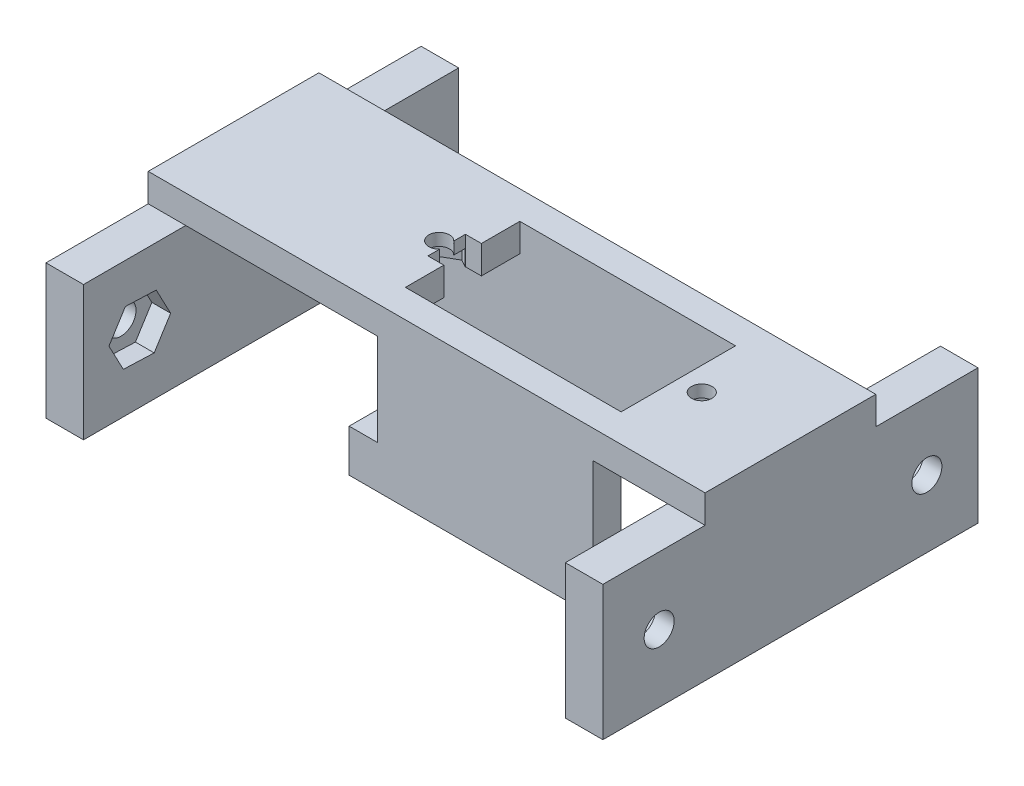
from build123d import *

# Parameters (mm, degrees)
BOSS_EXTRUDE1_DEPTH      = 3
SKETCH2_W                = 5
SKETCH2_H                = 3
SKETCH2_W_2              = 3
SKETCH2_H_2              = 4.533238731
BOSS_EXTRUDE2_DEPTH      = 15.2
BOSS_EXTRUDE3_DEPTH      = 3
BOSS_EXTRUDE4_DEPTH      = 19.425
BOSS_EXTRUDE5_DEPTH      = 6.955
CUT_EXTRUDE1_REACH       = 19.35
SKETCH6_R                = 1.1
CUT_EXTRUDE2_DEPTH       = 1.7
SKETCH8_W                = 4
SKETCH8_H                = 14.35
BOSS_EXTRUDE6_DEPTH      = 26.1
BOSS_EXTRUDE6_DEPTH_BACK = 13.9
SKETCH10_R               = 1.6
CUT_EXTRUDE3_DEPTH       = 56.38
CUT_EXTRUDE3_DEPTH_BACK  = 5
CUT_EXTRUDE5_START       = -2
CUT_EXTRUDE5_DEPTH       = 55.38
CUT_EXTRUDE6_DEPTH       = 7.5
CUT_EXTRUDE6_DEPTH_BACK  = 15.316761
CUT_EXTRUDE7_REACH       = 24.725
SKETCH13_W               = 4
SKETCH13_H               = 2.5


with BuildPart() as part:
    # Sketch1 → Boss-Extrude1 (new body)
    with BuildSketch(Plane.XY):
        Polygon((16.5, 0), (16.5, -3), (11.5, -3), (11.5, -12.816761269), (14.5, -12.816761269), (14.5, -17.35), (-14.5, -17.35), (-14.5, -12.816761269), (-11.5, -12.816761269), (-11.5, -3), (-16.5, -3), (-16.5, 0), align=None)
    extrude(amount=BOSS_EXTRUDE1_DEPTH)

    # Sketch2 → Boss-Extrude2 (add)
    with BuildSketch(Plane(origin=(0, 0, 0), x_dir=(-1, 0, 0), z_dir=(0, 0, -1))):
        with Locations((-14, -1.5)):
            Rectangle(SKETCH2_W, SKETCH2_H)
        with Locations((14, -1.5)):
            Rectangle(SKETCH2_W, SKETCH2_H)
        with Locations((-13, -15.083380635)):
            Rectangle(SKETCH2_W_2, SKETCH2_H_2)
        with Locations((13, -15.083380635)):
            Rectangle(SKETCH2_W_2, SKETCH2_H_2)
    extrude(amount=BOSS_EXTRUDE2_DEPTH)

    # Sketch3 → Boss-Extrude3 (add)
    with BuildSketch(Plane(origin=(0, 0, -12.2), x_dir=(-1, 0, 0), z_dir=(0, 0, -1))):
        Polygon((-11.5, -17.35), (16.5, -17.35), (16.5, 0), (-16.5, 0), (-16.5, -17.35), align=None)
    extrude(amount=BOSS_EXTRUDE3_DEPTH)

    # Sketch4 → Boss-Extrude4 (add)
    with BuildSketch(Plane.ZY.offset(16.5)):
        Polygon((-15.2, -17.35), (-12.2, -17.35), (-12.2, -3), (3, -3), (3, 0), (-15.2, 0), align=None)
    extrude(amount=BOSS_EXTRUDE4_DEPTH)

    # Sketch5 → Boss-Extrude5 (add)
    with BuildSketch(Plane(origin=(16.5, 0, 0), x_dir=(0, 0, -1), z_dir=(1, 0, 0))):
        Polygon((-3, 0), (15.2, 0), (15.2, -17.35), (12.2, -17.35), (12.2, -3), (-3, -3), align=None)
    extrude(amount=BOSS_EXTRUDE5_DEPTH)

    # Sketch6 → Cut-Extrude1 (cut, up to next)
    with BuildSketch(Plane(origin=(0, 0, 0), x_dir=(1, 0, 0), z_dir=(0, 1, 0)), mode=Mode.PRIVATE) as cut_extrude1_sk1:
        with Locations((14, 6.1)):
            Circle(SKETCH6_R)
    cut_extrude1_tool1 = extrude(cut_extrude1_sk1.sketch, amount=-CUT_EXTRUDE1_REACH, mode=Mode.PRIVATE) & part.part
    add(cut_extrude1_tool1.solids().sort_by_distance((14, 0, -6.1))[0], mode=Mode.SUBTRACT)
    # Sketch6 → Cut-Extrude1 (cut, up to next)
    with BuildSketch(Plane(origin=(0, 0, 0), x_dir=(1, 0, 0), z_dir=(0, 1, 0)), mode=Mode.PRIVATE) as cut_extrude1_sk2:
        with Locations((-14, 6.1)):
            Circle(SKETCH6_R)
    cut_extrude1_tool2 = extrude(cut_extrude1_sk2.sketch, amount=-CUT_EXTRUDE1_REACH, mode=Mode.PRIVATE) & part.part
    add(cut_extrude1_tool2.solids().sort_by_distance((-14, 0, -6.1))[0], mode=Mode.SUBTRACT)

    # Sketch7 → Cut-Extrude2 (cut)
    with BuildSketch(Plane.XZ.offset(3)):
        Polygon((14, -3.675128869), (11.9, -4.887564435), (11.9, -7.312435565), (14, -8.524871131), (16.1, -7.312435565), (16.1, -4.887564435), align=None)
        Polygon((-14, -3.675128869), (-16.1, -4.887564435), (-16.1, -7.312435565), (-14, -8.524871131), (-11.9, -7.312435565), (-11.9, -4.887564435), align=None)
    extrude(amount=-CUT_EXTRUDE2_DEPTH, mode=Mode.SUBTRACT)

    # Sketch8 → Boss-Extrude6 (add, two sides)
    with BuildSketch(Plane.XY.offset(-12.2)) as boss_extrude6_sk:
        with Locations((-33.925, -10.175)):
            Rectangle(SKETCH8_W, SKETCH8_H)
        with Locations((21.455, -10.175)):
            Rectangle(SKETCH8_W, SKETCH8_H)
    extrude(amount=BOSS_EXTRUDE6_DEPTH)
    extrude(boss_extrude6_sk.sketch, amount=-BOSS_EXTRUDE6_DEPTH_BACK)

    # Sketch10 → Cut-Extrude3 (cut, two sides)
    with BuildSketch(Plane(origin=(-31.925, 0, 0), x_dir=(0, 0, -1), z_dir=(1, 0, 0))) as cut_extrude3_sk:
        with Locations((-7.9, -10.175)):
            Circle(SKETCH10_R)
        with Locations((20.65, -10.175)):
            Circle(SKETCH10_R)
    extrude(amount=CUT_EXTRUDE3_DEPTH, mode=Mode.SUBTRACT)
    extrude(cut_extrude3_sk.sketch, amount=-CUT_EXTRUDE3_DEPTH_BACK, mode=Mode.SUBTRACT)

    # Sketch11 → Cut-Extrude5 (cut)
    with BuildSketch(Plane(origin=(-31.925, 0, 0), x_dir=(0, 0, -1), z_dir=(1, 0, 0)).offset(CUT_EXTRUDE5_START)):
        Polygon((-9.652389588, -12.960521627), (-6.363862302, -13.085374714), (-4.611472715, -10.299853087), (-6.147610412, -7.389478373), (-9.436137698, -7.264625286), (-11.188527285, -10.050146913), align=None)
        Polygon((20.65, -13.465896534), (23.5, -11.820448267), (23.5, -8.529551733), (20.65, -6.884103466), (17.8, -8.529551733), (17.8, -11.820448267), align=None)
    extrude(amount=CUT_EXTRUDE5_DEPTH, mode=Mode.SUBTRACT)

    # Sketch12 → Cut-Extrude6 (cut, two sides)
    with BuildSketch(Plane(origin=(0, 0, 0), x_dir=(1, 0, 0), z_dir=(0, 1, 0))) as cut_extrude6_sk:
        Polygon((-11.5, 6.1), (-11.5, 4.1), (-13.2, 4.1), (-13.2, 8.1), (-11.5, 8.1), align=None)
    extrude(amount=CUT_EXTRUDE6_DEPTH, mode=Mode.SUBTRACT)
    extrude(cut_extrude6_sk.sketch, amount=-CUT_EXTRUDE6_DEPTH_BACK, mode=Mode.SUBTRACT)

    # Sketch13 → Cut-Extrude7 (cut, up to next)
    with BuildSketch(Plane(origin=(-13.2, 0, 0), x_dir=(0, 0, -1), z_dir=(1, 0, 0)), mode=Mode.PRIVATE) as cut_extrude7_sk1:
        with Locations((6.1, -14.066761269)):
            Rectangle(SKETCH13_W, SKETCH13_H)
    cut_extrude7_tool1 = extrude(cut_extrude7_sk1.sketch, amount=-CUT_EXTRUDE7_REACH, mode=Mode.PRIVATE) & part.part
    add(cut_extrude7_tool1.solids().sort_by_distance((-13.2, -14.066761, -6.1))[0], mode=Mode.SUBTRACT)


solid = part.part
